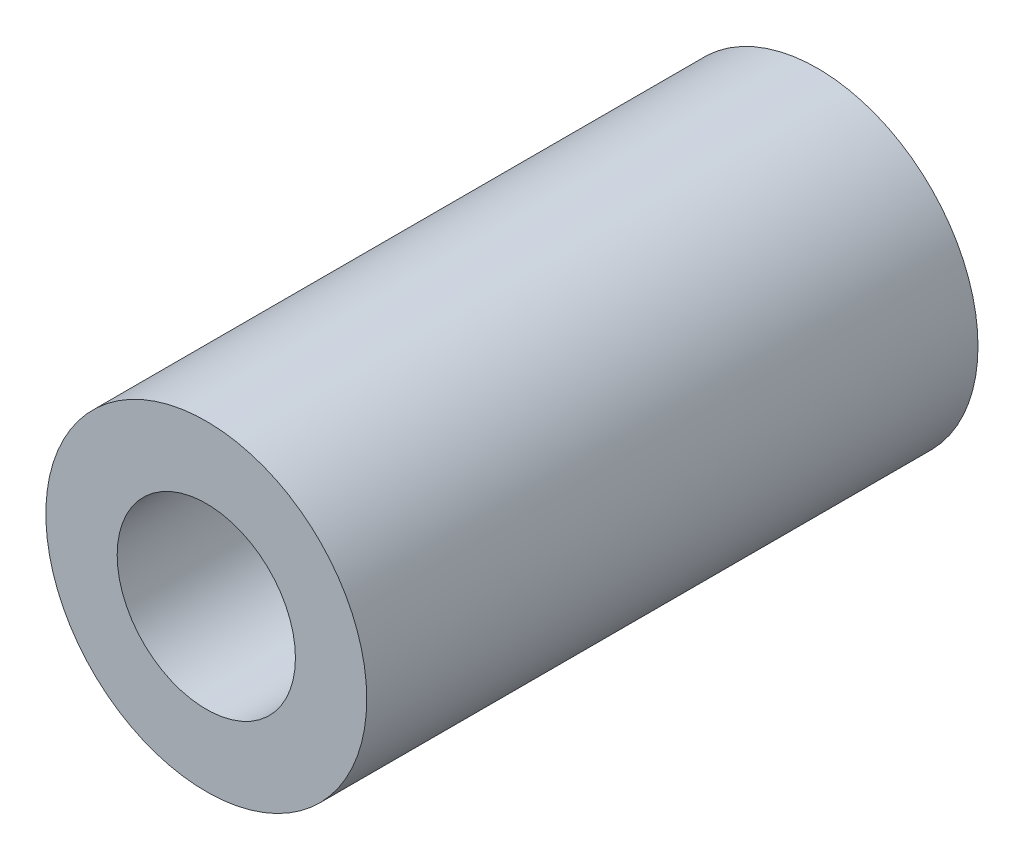
from build123d import *

# Parameters (mm, degrees)
SZKIC1_R                    = 3.15
SZKIC1_R_2                  = 1.75
DODANIE_WYCI_GNI_CIE1_DEPTH = 12


with BuildPart() as part:
    # Szkic1 → Dodanie-wyciągnięcie1 (new body)
    with BuildSketch(Plane.XY):
        Circle(SZKIC1_R)
        Circle(SZKIC1_R_2, mode=Mode.SUBTRACT)
    extrude(amount=DODANIE_WYCI_GNI_CIE1_DEPTH)


solid = part.part
